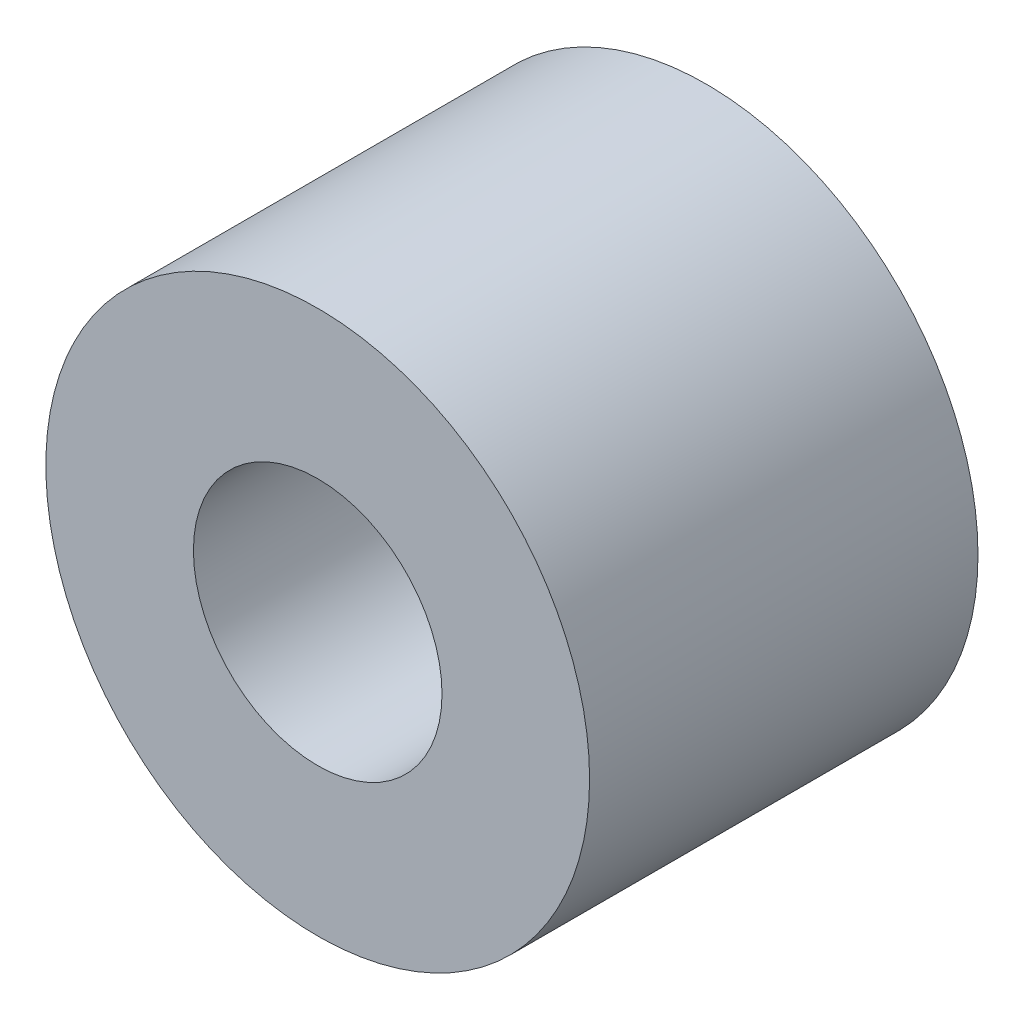
from build123d import *

# Parameters (mm, degrees)
SKETCH_1_R      = 3.5
SKETCH_1_R_2    = 1.6
EXTRUDE_1_DEPTH = 5


with BuildPart() as part:
    # ｽｹｯﾁ1 → ﾎﾞｽ - 押し出し1 (new body)
    with BuildSketch(Plane.XY):
        Circle(SKETCH_1_R)
        Circle(SKETCH_1_R_2, mode=Mode.SUBTRACT)
    extrude(amount=EXTRUDE_1_DEPTH)


solid = part.part
